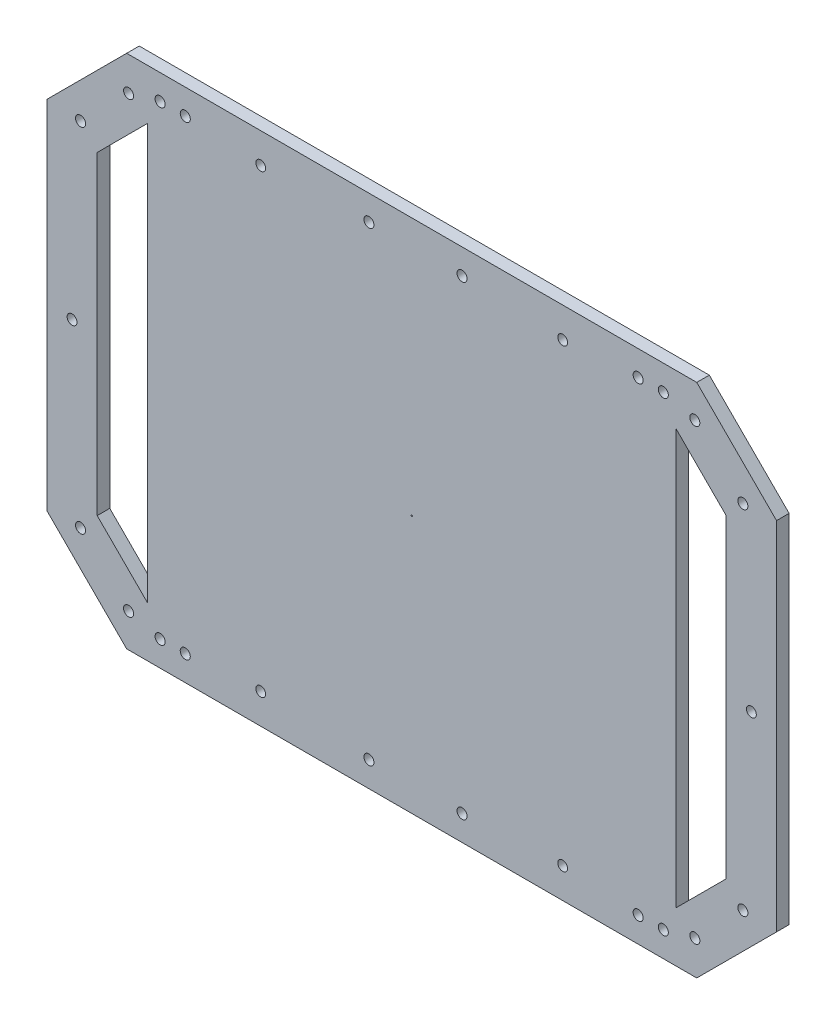
from build123d import *

# Parameters (mm, degrees)
SKETCH1_R           = 2
SKETCH1_R_2         = 1.95
SKETCH1_R_3         = 0.25
BOSS_EXTRUDE1_DEPTH = 5


with BuildPart() as part:
    # Sketch1 → Boss-Extrude1 (new body)
    with BuildSketch(Plane.XY):
        Polygon((-104.194627872, 87.590269756), (122.373914623, 87.590269756), (154.089643375, 55.874541003), (154.089643375, -85.694001492), (122.373914623, -117.409730244), (-104.194627872, -117.409730244), (-135.910356625, -85.694001492), (-135.910356625, 55.874541003), align=None)
        with Locations((121.614769641, 74.207279114)):
            Circle(SKETCH1_R, mode=Mode.SUBTRACT)
        with Locations((140.706652733, 55.115396022)):
            Circle(SKETCH1_R, mode=Mode.SUBTRACT)
        with Locations((-103.435482891, 74.207279114)):
            Circle(SKETCH1_R, mode=Mode.SUBTRACT)
        with Locations((-103.435482891, -104.026739602)):
            Circle(SKETCH1_R, mode=Mode.SUBTRACT)
        with Locations((-122.527365983, 55.115396022)):
            Circle(SKETCH1_R, mode=Mode.SUBTRACT)
        with Locations((-122.527365983, -84.93485651)):
            Circle(SKETCH1_R, mode=Mode.SUBTRACT)
        with Locations((121.614769641, -104.026739602)):
            Circle(SKETCH1_R, mode=Mode.SUBTRACT)
        with Locations((140.706652733, -84.93485651)):
            Circle(SKETCH1_R, mode=Mode.SUBTRACT)
        with Locations((29.089643375, 77.590269756)):
            Circle(SKETCH1_R, mode=Mode.SUBTRACT)
        with Locations((29.089643375, -107.409730244)):
            Circle(SKETCH1_R, mode=Mode.SUBTRACT)
        with Locations((-7.910356625, -107.409730244)):
            Circle(SKETCH1_R, mode=Mode.SUBTRACT)
        with Locations((-7.910356625, 77.590269756)):
            Circle(SKETCH1_R, mode=Mode.SUBTRACT)
        with Locations((-90.910356625, 77.590269756)):
            Circle(SKETCH1_R, mode=Mode.SUBTRACT)
        with Locations((109.089643375, -107.409730244)):
            Circle(SKETCH1_R, mode=Mode.SUBTRACT)
        with Locations((99.089643375, -107.409730244)):
            Circle(SKETCH1_R, mode=Mode.SUBTRACT)
        with Locations((-80.910356625, 77.590269756)):
            Circle(SKETCH1_R, mode=Mode.SUBTRACT)
        with Locations((-90.910356625, -107.409730244)):
            Circle(SKETCH1_R, mode=Mode.SUBTRACT)
        with Locations((-80.910356625, -107.409730244)):
            Circle(SKETCH1_R, mode=Mode.SUBTRACT)
        with Locations((99.089643375, 77.590269756)):
            Circle(SKETCH1_R, mode=Mode.SUBTRACT)
        with Locations((109.089643375, 77.590269756)):
            Circle(SKETCH1_R, mode=Mode.SUBTRACT)
        with Locations((69.089643375, 75.590269756)):
            Circle(SKETCH1_R_2, mode=Mode.SUBTRACT)
        with Locations((-50.910356625, 75.590269756)):
            Circle(SKETCH1_R_2, mode=Mode.SUBTRACT)
        with Locations((-50.910356625, -105.409730244)):
            Circle(SKETCH1_R_2, mode=Mode.SUBTRACT)
        with Locations((69.089643375, -105.409730244)):
            Circle(SKETCH1_R_2, mode=Mode.SUBTRACT)
        with Locations((144.089643375, -14.909730244)):
            Circle(SKETCH1_R_2, mode=Mode.SUBTRACT)
        with Locations((-125.910356625, -14.909730244)):
            Circle(SKETCH1_R_2, mode=Mode.SUBTRACT)
        with Locations((9.089643375, -14.909730244)):
            Circle(SKETCH1_R_3, mode=Mode.SUBTRACT)
        Polygon((134.089643375, 47.590269756), (134.089643375, -77.409730244), (114.089643375, -97.409730244), (114.089643375, 67.590269756), align=None, mode=Mode.SUBTRACT)
        Polygon((-115.910356625, 47.590269756), (-115.910356625, -77.409730244), (-95.910356625, -97.409730244), (-95.910356625, 67.590269756), align=None, mode=Mode.SUBTRACT)
    extrude(amount=BOSS_EXTRUDE1_DEPTH)


solid = part.part
